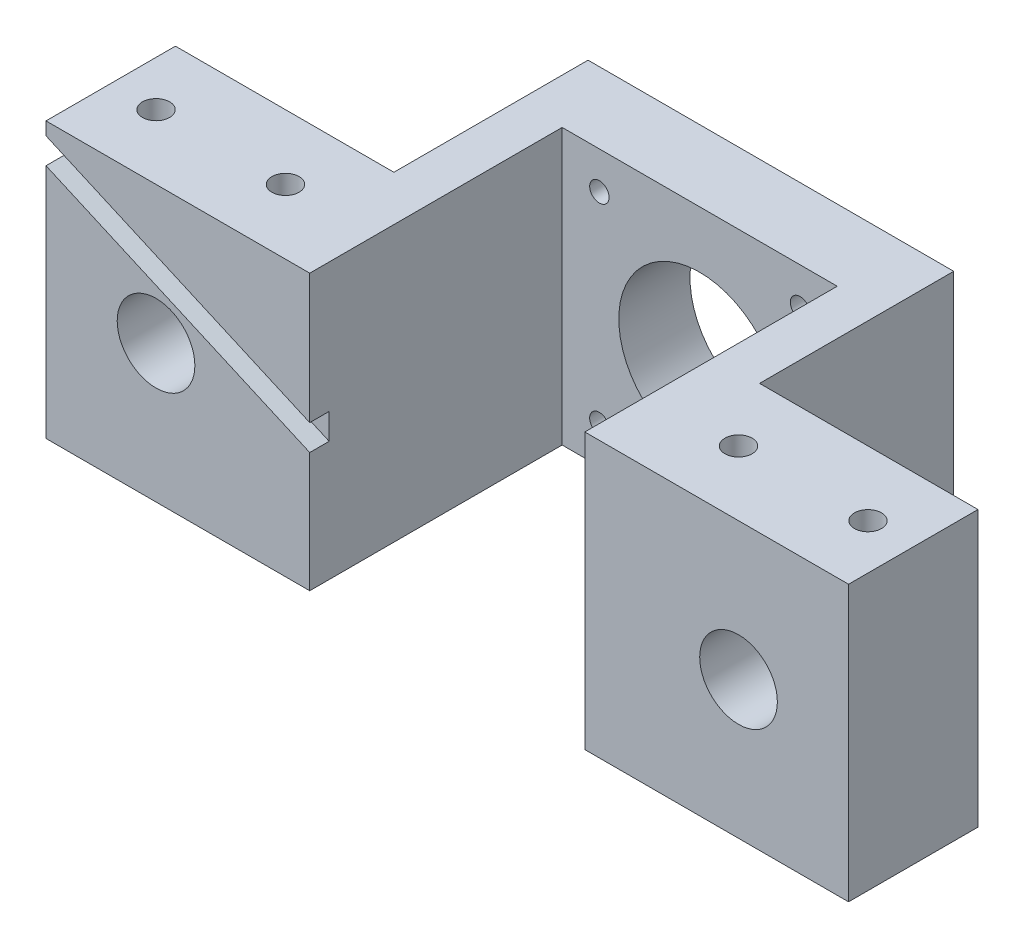
from build123d import *

# Parameters (mm, degrees)
SKETCH2_W           = 124
SKETCH2_H           = 42.5
SKETCH2_R           = 12.5
SKETCH2_R_2         = 6
SKETCH2_R_3         = 1.5
BOSS_EXTRUDE1_DEPTH = 50
SKETCH3_W           = 42.5
SKETCH3_H           = 42.5
CUT_EXTRUDE1_DEPTH  = 39
SKETCH4_W           = 33.75
SKETCH4_H           = 42.5
CUT_EXTRUDE2_DEPTH  = 30
CUT_EXTRUDE3_REACH  = 44.5
SKETCH5_R           = 2.1
CUT_EXTRUDE4_DEPTH  = 3


with BuildPart() as part:
    # Sketch2 → Boss-Extrude1 (new body)
    with BuildSketch(Plane.XY):
        with Locations((62, 21.25)):
            Rectangle(SKETCH2_W, SKETCH2_H)
        with Locations((62, 21.25)):
            Circle(SKETCH2_R, mode=Mode.SUBTRACT)
        with Locations((107, 21.25)):
            Circle(SKETCH2_R_2, mode=Mode.SUBTRACT)
        with Locations((17, 21.25)):
            Circle(SKETCH2_R_2, mode=Mode.SUBTRACT)
        with Locations((46.5, 36.75)):
            Circle(SKETCH2_R_3, mode=Mode.SUBTRACT)
        with Locations((77.5, 36.75)):
            Circle(SKETCH2_R_3, mode=Mode.SUBTRACT)
        with Locations((77.5, 5.75)):
            Circle(SKETCH2_R_3, mode=Mode.SUBTRACT)
        with Locations((46.5, 5.75)):
            Circle(SKETCH2_R_3, mode=Mode.SUBTRACT)
    extrude(amount=BOSS_EXTRUDE1_DEPTH)

    # Sketch3 → Cut-Extrude1 (cut)
    with BuildSketch(Plane.XY.offset(50)):
        with Locations((62, 21.25)):
            Rectangle(SKETCH3_W, SKETCH3_H)
    extrude(amount=-CUT_EXTRUDE1_DEPTH, mode=Mode.SUBTRACT)

    # Sketch4 → Cut-Extrude2 (cut)
    with BuildSketch(Plane(origin=(0, 0, 0), x_dir=(-1, 0, 0), z_dir=(0, 0, -1))):
        with Locations((-107.125, 21.25)):
            Rectangle(SKETCH4_W, SKETCH4_H)
        with Locations((-16.875, 21.25)):
            Rectangle(SKETCH4_W, SKETCH4_H)
    extrude(amount=-CUT_EXTRUDE2_DEPTH, mode=Mode.SUBTRACT)

    # Sketch5 → Cut-Extrude3 (cut, up to next)
    with BuildSketch(Plane.XZ, mode=Mode.PRIVATE) as cut_extrude3_sk1:
        with Locations((7, 40)):
            Circle(SKETCH5_R)
    cut_extrude3_tool1 = extrude(cut_extrude3_sk1.sketch, amount=-CUT_EXTRUDE3_REACH, mode=Mode.PRIVATE) & part.part
    add(cut_extrude3_tool1.solids().sort_by_distance((7, 0, 40))[0], mode=Mode.SUBTRACT)
    # Sketch5 → Cut-Extrude3 (cut, up to next)
    with BuildSketch(Plane.XZ, mode=Mode.PRIVATE) as cut_extrude3_sk2:
        with Locations((27, 40)):
            Circle(SKETCH5_R)
    cut_extrude3_tool2 = extrude(cut_extrude3_sk2.sketch, amount=-CUT_EXTRUDE3_REACH, mode=Mode.PRIVATE) & part.part
    add(cut_extrude3_tool2.solids().sort_by_distance((27, 0, 40))[0], mode=Mode.SUBTRACT)
    # Sketch5 → Cut-Extrude3 (cut, up to next)
    with BuildSketch(Plane.XZ, mode=Mode.PRIVATE) as cut_extrude3_sk3:
        with Locations((97, 40)):
            Circle(SKETCH5_R)
    cut_extrude3_tool3 = extrude(cut_extrude3_sk3.sketch, amount=-CUT_EXTRUDE3_REACH, mode=Mode.PRIVATE) & part.part
    add(cut_extrude3_tool3.solids().sort_by_distance((97, 0, 40))[0], mode=Mode.SUBTRACT)
    # Sketch5 → Cut-Extrude3 (cut, up to next)
    with BuildSketch(Plane.XZ, mode=Mode.PRIVATE) as cut_extrude3_sk4:
        with Locations((117, 40)):
            Circle(SKETCH5_R)
    cut_extrude3_tool4 = extrude(cut_extrude3_sk4.sketch, amount=-CUT_EXTRUDE3_REACH, mode=Mode.PRIVATE) & part.part
    add(cut_extrude3_tool4.solids().sort_by_distance((117, 0, 40))[0], mode=Mode.SUBTRACT)
    # Sketch5 → Cut-Extrude3 (cut, up to next)
    with BuildSketch(Plane.XZ, mode=Mode.PRIVATE) as cut_extrude3_sk5:
        with Locations((17, 40)):
            Circle(SKETCH5_R)
    cut_extrude3_tool5 = extrude(cut_extrude3_sk5.sketch, amount=-CUT_EXTRUDE3_REACH, mode=Mode.PRIVATE) & part.part
    add(cut_extrude3_tool5.solids().sort_by_distance((17, 0, 40))[0], mode=Mode.SUBTRACT)
    # Sketch5 → Cut-Extrude3 (cut, up to next)
    with BuildSketch(Plane.XZ, mode=Mode.PRIVATE) as cut_extrude3_sk6:
        with Locations((107, 40)):
            Circle(SKETCH5_R)
    cut_extrude3_tool6 = extrude(cut_extrude3_sk6.sketch, amount=-CUT_EXTRUDE3_REACH, mode=Mode.PRIVATE) & part.part
    add(cut_extrude3_tool6.solids().sort_by_distance((107, 0, 40))[0], mode=Mode.SUBTRACT)

    # Sketch7 → Cut-Extrude4 (cut)
    with BuildSketch(Plane.XY.offset(50)):
        Polygon((0, 40.5), (40.75, 22.5), (40.75, 18.5), (0, 36.5), align=None)
    extrude(amount=-CUT_EXTRUDE4_DEPTH, mode=Mode.SUBTRACT)


solid = part.part
